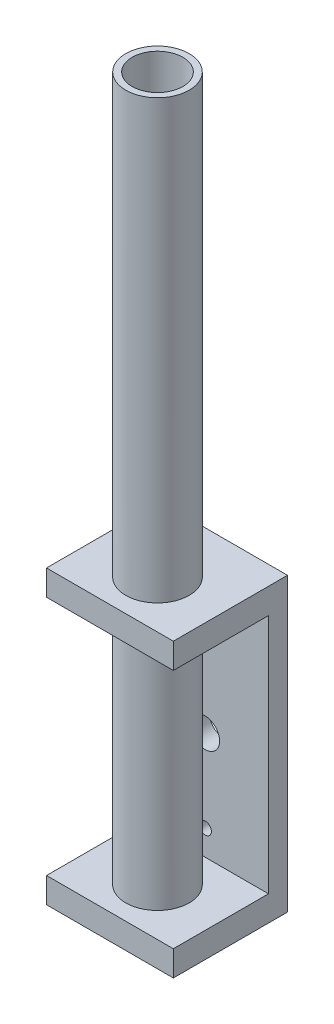
from build123d import *

# Parameters (mm, degrees)
SKETCH1_W           = 20
SKETCH1_H           = 46
SKETCH1_R           = 0.955
SKETCH1_R_2         = 2.3
BOSS_EXTRUDE1_DEPTH = 3
SKETCH2_W           = 20
SKETCH2_H           = 15
SKETCH2_R           = 4
BOSS_EXTRUDE2_DEPTH = 4
SKETCH4_R           = 5
SKETCH4_R_2         = 4
BOSS_EXTRUDE4_DEPTH = 115
BOSS_EXTRUDE6_START = -4
SKETCH5_W           = 20
SKETCH5_H           = 15
SKETCH5_R           = 4
BOSS_EXTRUDE6_DEPTH = 4
SKETCH4_3_R         = 3.25
SKETCH4_3_R_2       = 2
BOSS_EXTRUDE7_DEPTH = 2
SKETCH4_4_R         = 4
SKETCH4_4_R_2       = 3.25
BOSS_EXTRUDE8_DEPTH = 3


with BuildPart() as part:
    # Sketch1 → Boss-Extrude1 (new body)
    with BuildSketch(Plane.XY):
        with Locations((11.641947403, 2)):
            Rectangle(SKETCH1_W, SKETCH1_H)
        with Locations((11.599686328, 13)):
            Circle(SKETCH1_R, mode=Mode.SUBTRACT)
        with Locations((11.684208477, -13)):
            Circle(SKETCH1_R, mode=Mode.SUBTRACT)
        with Locations((11.641947403, 0)):
            Circle(SKETCH1_R_2, mode=Mode.SUBTRACT)
    extrude(amount=BOSS_EXTRUDE1_DEPTH)

    # Sketch2 → Boss-Extrude2 (add)
    with BuildSketch(Plane.XZ.offset(21)):
        with Locations((11.641947403, 10.5)):
            Rectangle(SKETCH2_W, SKETCH2_H)
        with Locations((11.641947403, 10.5)):
            Circle(SKETCH2_R, mode=Mode.SUBTRACT)
    extrude(amount=-BOSS_EXTRUDE2_DEPTH)

    # Sketch4 → Boss-Extrude4 (add)
    with BuildSketch(Plane.XZ.offset(21)):
        with Locations((11.641947403, 10.5)):
            Circle(SKETCH4_R)
        with Locations((11.641947403, 10.5)):
            Circle(SKETCH4_R_2, mode=Mode.SUBTRACT)
    extrude(amount=-BOSS_EXTRUDE4_DEPTH)

    # Sketch5 → Boss-Extrude6 (add)
    with BuildSketch(Plane(origin=(0, 25, 0), x_dir=(1, 0, 0), z_dir=(0, 1, 0)).offset(BOSS_EXTRUDE6_START)):
        with Locations((11.641947403, -10.5)):
            Rectangle(SKETCH5_W, SKETCH5_H)
        with Locations((11.641947403, -10.5)):
            Circle(SKETCH5_R, mode=Mode.SUBTRACT)
    extrude(amount=BOSS_EXTRUDE6_DEPTH)



with BuildPart() as body_2:
    # Sketch4_3 → Boss-Extrude7 (new body)
    with BuildSketch(Plane.XZ.offset(21)):
        with Locations((11.641947403, 10.5)):
            Circle(SKETCH4_3_R)
        with Locations((11.641947403, 10.5)):
            Circle(SKETCH4_3_R_2, mode=Mode.SUBTRACT)
    extrude(amount=-BOSS_EXTRUDE7_DEPTH)


with BuildPart() as part_1:
    add(part.part)

    add(body_2.part)  # Boss-Extrude8 merges body 2
    # Sketch4_4 → Boss-Extrude8 (add)
    with BuildSketch(Plane.XZ.offset(21)):
        with Locations((11.641947403, 10.5)):
            Circle(SKETCH4_4_R)
        with Locations((11.641947403, 10.5)):
            Circle(SKETCH4_4_R_2, mode=Mode.SUBTRACT)
    extrude(amount=-BOSS_EXTRUDE8_DEPTH)


solid = part_1.part
